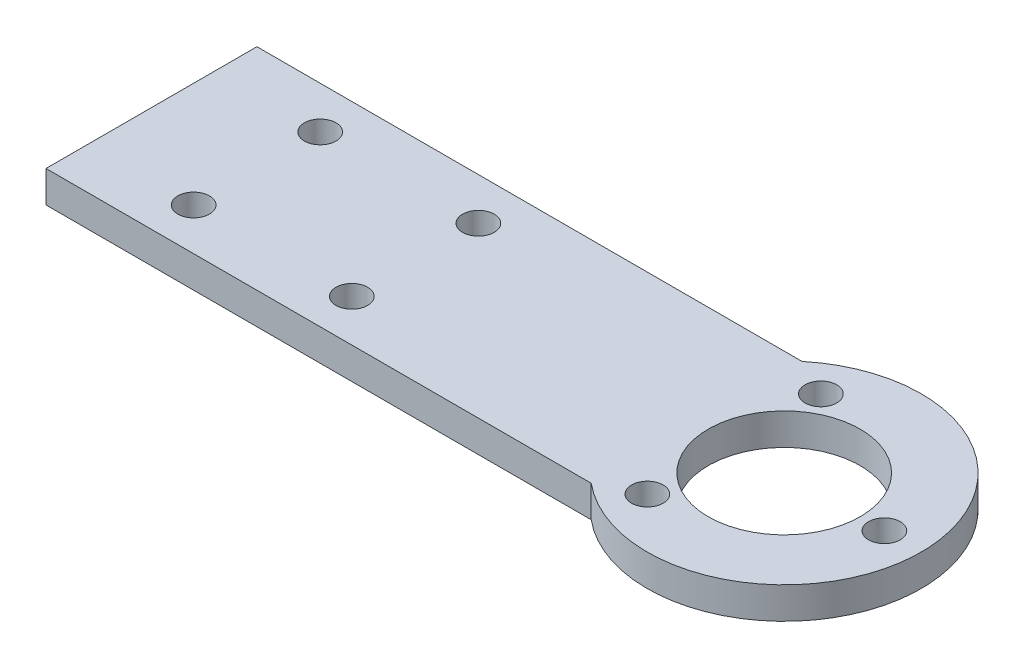
from build123d import *

# Parameters (mm, degrees)
SKETCH_1_R      = 1.5
SKETCH_1_R_2    = 7.2
EXTRUDE_1_DEPTH = 3


with BuildPart() as part:
    # 草图1 → 凸台-拉伸1 (new body)
    with BuildSketch(Plane(origin=(0, 0, 0), x_dir=(1, 0, 0), z_dir=(0, 1, 0))):
        with BuildLine():
            Line((-58.582677165, 11.57480315), (-6.889301028, 11.57480315))
            ThreePointArc((-6.889301028, 11.57480315), (14.417322835, 1.57480315), (-6.889301028, -8.42519685))
            Line((-6.889301028, -8.42519685), (-58.582677165, -8.42519685))
            Line((-58.582677165, -8.42519685), (-58.582677165, 11.57480315))
        make_face()
        with Locations((-33.582677165, 7.57480315)):
            Circle(SKETCH_1_R, mode=Mode.SUBTRACT)
        with Locations((-48.582677165, 7.57480315)):
            Circle(SKETCH_1_R, mode=Mode.SUBTRACT)
        with Locations((-33.582677165, -4.42519685)):
            Circle(SKETCH_1_R, mode=Mode.SUBTRACT)
        with Locations((-48.582677165, -4.42519685)):
            Circle(SKETCH_1_R, mode=Mode.SUBTRACT)
        with Locations((1.417322835, 1.57480315)):
            Circle(SKETCH_1_R_2, mode=Mode.SUBTRACT)
        with Locations((10.917322835, 1.57480315)):
            Circle(SKETCH_1_R, mode=Mode.SUBTRACT)
        with Locations((-3.332677165, -6.652438186)):
            Circle(SKETCH_1_R, mode=Mode.SUBTRACT)
        with Locations((-3.332677165, 9.802044486)):
            Circle(SKETCH_1_R, mode=Mode.SUBTRACT)
    extrude(amount=EXTRUDE_1_DEPTH)


solid = part.part
